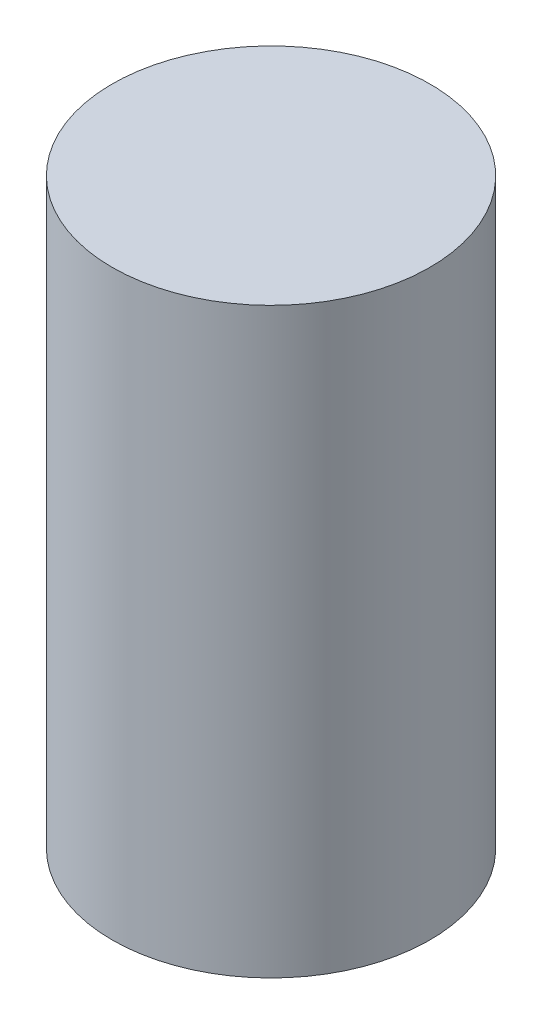
from build123d import *

# Parameters (mm, degrees)
SKETCH1_R           = 3
BOSS_EXTRUDE1_DEPTH = 11


with BuildPart() as part:
    # Sketch1 → Boss-Extrude1 (new body)
    with BuildSketch(Plane(origin=(0, 0, 0), x_dir=(1, 0, 0), z_dir=(0, 1, 0))):
        Circle(SKETCH1_R)
    extrude(amount=BOSS_EXTRUDE1_DEPTH)


solid = part.part
